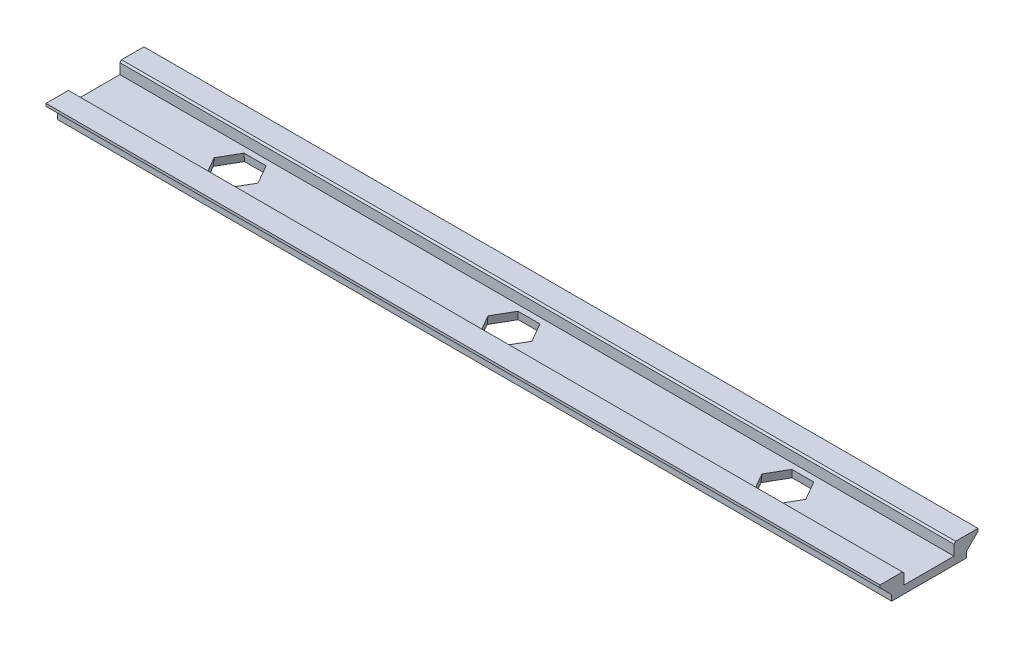
from build123d import *

# Parameters (mm, degrees)
BOSS_EXTRUDE1_DEPTH = 50.25
CUT_EXTRUDE2_DEPTH  = 3.4
CUT_EXTRUDE2_TAPER  = -5
CHAMFER1_SIZE       = 0.2


with BuildPart() as part:
    # Retainer Profile → Boss-Extrude1 (new body, symmetric)
    with BuildSketch(Plane(origin=(0, 0, 0), x_dir=(0, 0, -1), z_dir=(1, 0, 0))):
        Polygon((-5.1, 4.592304845), (-5.9, 4.592304845), (-5.9, 4.275147558), (-4.5, 2.875147558), (-4.5, 2.192304845), (4.5, 2.192304845), (4.5, 2.875147558), (5.9, 4.275147558), (5.9, 4.592304845), (5.1, 4.592304845), (3, 4.592304845), (3, 3.142304845), (-3, 3.142304845), (-3, 4.592304845), align=None)
    extrude(amount=BOSS_EXTRUDE1_DEPTH, both=True)

    # Sketch3 → Cut-Extrude2 (cut, through all)
    with BuildSketch(Plane(origin=(0, 4.592304845, 0), x_dir=(1, 0, 0), z_dir=(0, 1, 0))):
        Polygon((35.25, 0), (34, 2.165063509), (31.5, 2.165063509), (30.25, 0), (31.5, -2.165063509), (34, -2.165063509), align=None)
        Polygon((2.25, 0), (1, 2.165063509), (-1.5, 2.165063509), (-2.75, 0), (-1.5, -2.165063509), (1, -2.165063509), align=None)
        Polygon((-30.75, 0), (-32, 2.165063509), (-34.5, 2.165063509), (-35.75, 0), (-34.5, -2.165063509), (-32, -2.165063509), align=None)
    extrude(amount=-CUT_EXTRUDE2_DEPTH, taper=CUT_EXTRUDE2_TAPER, mode=Mode.SUBTRACT)

    # Chamfer1
    chamfer1_edges = [part.edges().sort_by_distance(p)[0] for p in [
        (0, 4.592304845, 3),
        (0, 4.592304845, -3),
    ]]
    chamfer(chamfer1_edges, length=CHAMFER1_SIZE)


solid = part.part
